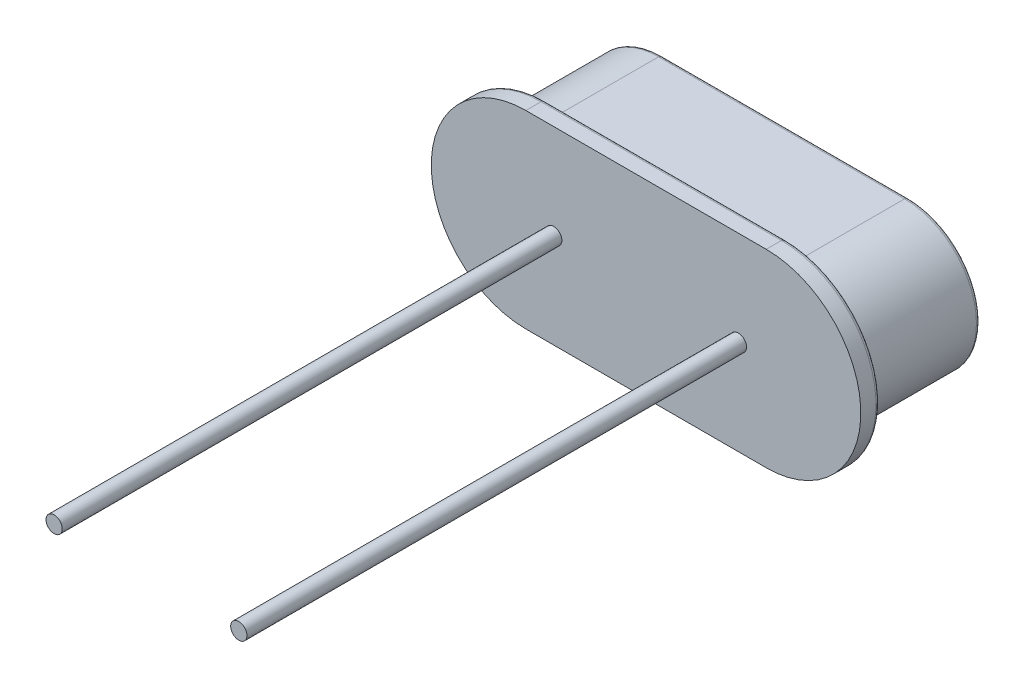
from build123d import *

# Parameters (mm, degrees)
BOSS_EXTRUDE1_DEPTH = 0.5
BOSS_EXTRUDE2_DEPTH = 3.18
SKETCH4_R           = 0.215
BOSS_EXTRUDE3_DEPTH = 13.2
FILLET5_R           = 0.1
FILLET6_R           = 0.1


with BuildPart() as part:
    # Sketch1 → Boss-Extrude1 (new body)
    with BuildSketch(Plane.XY):
        with BuildLine():
            Line((-3.175, 2.5), (3.175, 2.5))
            ThreePointArc((3.175, 2.5), (5.675, 0), (3.175, -2.5))
            Line((3.175, -2.5), (-3.175, -2.5))
            ThreePointArc((-3.175, -2.5), (-5.675, 0), (-3.175, 2.5))
        make_face()
    extrude(amount=-BOSS_EXTRUDE1_DEPTH)

    # Sketch3 → Boss-Extrude2 (add)
    with BuildSketch(Plane(origin=(0, 0, -0.5), x_dir=(-1, 0, 0), z_dir=(0, 0, -1))):
        with BuildLine():
            Line((-3.25, 1.9), (3.25, 1.9))
            ThreePointArc((3.25, 1.9), (5.15, 0), (3.25, -1.9))
            Line((3.25, -1.9), (-3.25, -1.9))
            ThreePointArc((-3.25, -1.9), (-5.15, 0), (-3.25, 1.9))
        make_face()
    extrude(amount=BOSS_EXTRUDE2_DEPTH)

    # Sketch4 → Boss-Extrude3 (add)
    with BuildSketch(Plane.XY):
        with Locations((-2.44, 0)):
            Circle(SKETCH4_R)
        with Locations((2.44, 0)):
            Circle(SKETCH4_R)
    extrude(amount=BOSS_EXTRUDE3_DEPTH)

    # Fillet5
    fillet5_edges = [part.edges().sort_by_distance(p)[0] for p in [
        (5.15, 0, -3.68),
        (0, -1.9, -3.68),
        (-5.15, 0, -3.68),
        (0, 1.9, -3.68),
    ]]
    fillet(fillet5_edges, radius=FILLET5_R)

    # Fillet6
    fillet6_edges = [part.edges().sort_by_distance(p)[0] for p in [
        (5.675, 0, -0.5),
        (0, 2.5, -0.5),
        (-5.675, 0, -0.5),
        (0, -2.5, -0.5),
    ]]
    fillet(fillet6_edges, radius=FILLET6_R)


solid = part.part
